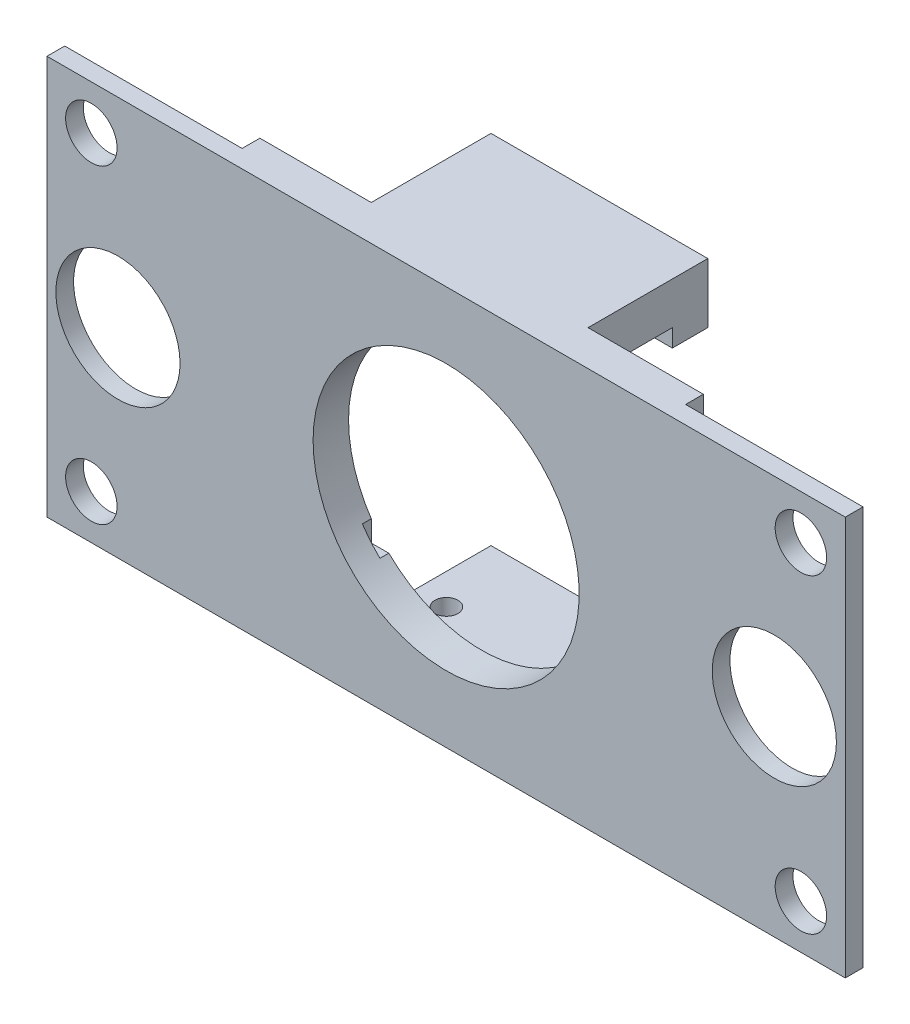
from build123d import *

# Parameters (mm, degrees)
SKETCH_1_W          = 90
SKETCH_1_H          = 45
SKETCH_1_R          = 2.9
SKETCH_1_R_2        = 7
EXTRUDE_2_DEPTH     = 2
EXTRUDE_3_DEPTH     = 2
SKETCH_3_R          = 15
CUT_EXTRUDE_1_DEPTH = 51.470288289
SKETCH_4_W          = 24.441241248
SKETCH_4_H          = 13
CUT_EXTRUDE_2_DEPTH = 1
EXTRUDE_4_DEPTH     = 13.5
SKETCH_5_R          = 1.3
CUT_EXTRUDE_3_DEPTH = 63.859466272
SKETCH_4_4_W        = 24.441241248
SKETCH_4_4_H        = 4.75
EXTRUDE_5_DEPTH     = 13.5
SKETCH_6_W          = 24.441241248
SKETCH_6_H          = 4
EXTRUDE_6_DEPTH     = 2


with BuildPart() as part:
    # 草图1 → 凸台-拉伸2 (new body)
    with BuildSketch(Plane.XY):
        Rectangle(SKETCH_1_W, SKETCH_1_H)
        with Locations((-40, 17.5)):
            Circle(SKETCH_1_R, mode=Mode.SUBTRACT)
        with Locations((-40, -17.5)):
            Circle(SKETCH_1_R, mode=Mode.SUBTRACT)
        with Locations((40, 17.5)):
            Circle(SKETCH_1_R, mode=Mode.SUBTRACT)
        with Locations((40, -17.5)):
            Circle(SKETCH_1_R, mode=Mode.SUBTRACT)
        with Locations((-37, 0)):
            Circle(SKETCH_1_R_2, mode=Mode.SUBTRACT)
        with Locations((37, 0)):
            Circle(SKETCH_1_R_2, mode=Mode.SUBTRACT)
    extrude(amount=-EXTRUDE_2_DEPTH)

    # 草图2 → 凸台-拉伸3 (add)
    with BuildSketch(Plane(origin=(0, 0, -2), x_dir=(-1, 0, 0), z_dir=(0, 0, -1))):
        Polygon((0, -22.5), (-25, -22.5), (-25, 22.5), (25, 22.5), (25, -22.5), align=None)
    extrude(amount=EXTRUDE_3_DEPTH)

    # 草图3 → 切除-拉伸1 (cut, through all)
    with BuildSketch(Plane(origin=(0, 0, -4), x_dir=(-1, 0, 0), z_dir=(0, 0, -1))):
        Circle(SKETCH_3_R)
    extrude(amount=-CUT_EXTRUDE_1_DEPTH, mode=Mode.SUBTRACT)

    # 草图4 → 切除-拉伸2 (cut)
    with BuildSketch(Plane(origin=(0, 0, -4), x_dir=(-1, 0, 0), z_dir=(0, 0, -1))):
        with Locations((0.220620624, -4.25)):
            Rectangle(SKETCH_4_W, SKETCH_4_H)
    extrude(amount=-CUT_EXTRUDE_2_DEPTH, mode=Mode.SUBTRACT)

    # 草图4<3> → 凸台-拉伸4 (add)
    with BuildSketch(Plane(origin=(0, 0, -4), x_dir=(-1, 0, 0), z_dir=(0, 0, -1))):
        Polygon((-12, -22.5), (0, -22.5), (12.441241248, -22.5), (12.441241248, -17.75), (-12, -17.75), align=None)
    extrude(amount=EXTRUDE_4_DEPTH)

    # 草图5 → 切除-拉伸3 (cut, through all)
    with BuildSketch(Plane(origin=(0, -17.75, 0), x_dir=(1, 0, 0), z_dir=(0, 1, 0))):
        with Locations((-8.970620624, 9)):
            Circle(SKETCH_5_R)
        with Locations((8.529379376, 9)):
            Circle(SKETCH_5_R)
    extrude(amount=-CUT_EXTRUDE_3_DEPTH, mode=Mode.SUBTRACT)

    # 草图4<4> → 凸台-拉伸5 (add)
    with BuildSketch(Plane(origin=(0, 0, -4), x_dir=(-1, 0, 0), z_dir=(0, 0, -1))):
        with Locations((0.220620624, 20.125)):
            Rectangle(SKETCH_4_4_W, SKETCH_4_4_H)
    extrude(amount=EXTRUDE_5_DEPTH)

    # 草图6 → 凸台-拉伸6 (add)
    with BuildSketch(Plane.XZ.offset(-17.75)):
        with Locations((-0.220620624, -15.5)):
            Rectangle(SKETCH_6_W, SKETCH_6_H)
    extrude(amount=EXTRUDE_6_DEPTH)


solid = part.part
